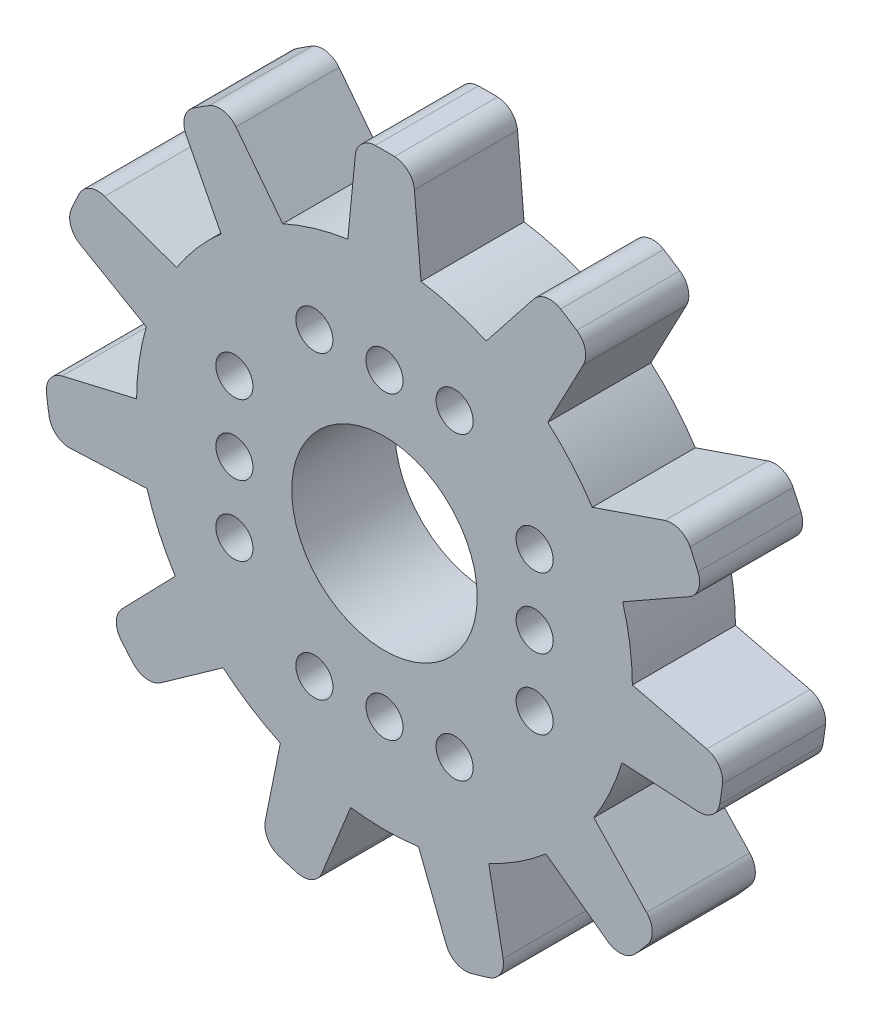
from build123d import *

# Parameters (mm, degrees)
ESBO_O1_R                = 4.5
RESSALTO_EXTRUS_O1_DEPTH = 5
ESBO_O3_R                = 0.9
CORTE_EXTRUS_O4_DEPTH    = 11.8
ESBO_O5_W                = 1.8
ESBO_O5_H                = 6.8
CORTE_EXTRUS_O5_DEPTH    = 1


with BuildPart() as part:
    # Esboço1 → Ressalto-extrusão1 (new body)
    with BuildSketch(Plane.XY):
        with BuildLine():
            Line((7.237292739, 13.882644275), (4.931205446, 10.964033635))
            ThreePointArc((4.931205446, 10.964033635), (3.383365404, 11.536015744), (1.77178072, 11.89065237))
            Line((1.77178072, 11.89065237), (1.451023847, 15.579942687))
            ThreePointArc((1.451023847, 15.579942687), (1.141313879, 16.220426504), (0.484122849, 16.4928962))
            ThreePointArc((0.484122849, 16.4928962), (0.017522037, 16.499990696), (-0.449092791, 16.493887221))
            ThreePointArc((-0.449092791, 16.493887221), (-1.103704511, 16.225768855), (-1.417126065, 15.591599404))
            Line((-1.417126065, 15.591599404), (-1.779210104, 11.889542973))
            ThreePointArc((-1.779210104, 11.889542973), (-3.390572883, 11.533899437), (-4.938055227, 10.960950291))
            Line((-4.938055227, 10.960950291), (-7.202474013, 13.891164545))
            ThreePointArc((-7.202474013, 13.891164545), (-7.809290312, 14.262531969), (-8.509462826, 14.136443768))
            ThreePointArc((-8.509462826, 14.136443768), (-8.905827982, 13.890148593), (-9.295069567, 13.632743002))
            ThreePointArc((-9.295069567, 13.632743002), (-9.700808257, 13.053277663), (-9.621617356, 12.350331887))
            Line((-9.621617356, 12.350331887), (-7.924739018, 9.040206424))
            ThreePointArc((-7.924739018, 9.040206424), (-9.088028236, 7.869851554), (-10.08009353, 6.55122394))
            Line((-10.08009353, 6.55122394), (-13.569237263, 7.792039811))
            ThreePointArc((-13.569237263, 7.792039811), (-14.280500006, 7.776384308), (-14.80135418, 7.291770323))
            ThreePointArc((-14.80135418, 7.291770323), (-15.001640543, 6.870282455), (-15.189927432, 6.443299203))
            ThreePointArc((-15.189927432, 6.443299203), (-15.217973923, 5.736463043), (-14.771313119, 5.187921259))
            Line((-14.771313119, 5.187921259), (-11.554219287, 3.320668211))
            ThreePointArc((-11.554219287, 3.320668211), (-11.900098837, 1.707181407), (-12.02177336, 0.061530278))
            Line((-12.02177336, 0.061530278), (-15.627863558, -0.781002507))
            ThreePointArc((-15.627863558, -0.781002507), (-16.21775185, -1.178710425), (-16.393920163, -1.867988679))
            ThreePointArc((-16.393920163, -1.867988679), (-16.334538228, -2.330849819), (-16.262090664, -2.791846566))
            ThreePointArc((-16.262090664, -2.791846566), (-15.903540395, -3.401638061), (-15.231221337, -3.621617713))
            Line((-15.231221337, -3.621617713), (-11.51531657, -3.453158696))
            ThreePointArc((-11.51531657, -3.453158696), (-10.93397214, -4.997506773), (-10.14662509, -6.447698813))
            Line((-10.14662509, -6.447698813), (-12.724753595, -9.106082048))
            ThreePointArc((-12.724753595, -9.106082048), (-13.005982071, -9.759572927), (-12.781532328, -10.434674473))
            ThreePointArc((-12.781532328, -10.434674473), (-12.48133544, -10.791953745), (-12.171155012, -11.140600777))
            ThreePointArc((-12.171155012, -11.140600777), (-11.53984516, -11.459743115), (-10.855324398, -11.28131865))
            Line((-10.855324398, -11.28131865), (-7.820382206, -9.130632116))
            ThreePointArc((-7.820382206, -9.130632116), (-6.496386543, -10.115521864), (-5.049995046, -10.909829088))
            Line((-5.049995046, -10.909829088), (-5.781624274, -14.540044879))
            ThreePointArc((-5.781624274, -14.540044879), (-5.664904879, -15.241839982), (-5.111098288, -15.68842485))
            ThreePointArc((-5.111098288, -15.68842485), (-4.665396838, -15.826688609), (-4.215963642, -15.952292956))
            ThreePointArc((-4.215963642, -15.952292956), (-3.512330623, -15.879460702), (-3.032938663, -15.359280625))
            Line((-3.032938663, -15.359280625), (-1.642531748, -11.909194354))
            ThreePointArc((-1.642531748, -11.909194354), (0.003755879, -12.021930236), (1.649972743, -11.908165713))
            Line((1.649972743, -11.908165713), (2.997129903, -15.357646195))
            ThreePointArc((2.997129903, -15.357646195), (3.474739585, -15.884930537), (4.182073344, -15.961211187))
            ThreePointArc((4.182073344, -15.961211187), (4.631772295, -15.836561666), (5.077766396, -15.699244836))
            ThreePointArc((5.077766396, -15.699244836), (5.630324069, -15.257561714), (5.752383667, -14.560779526))
            Line((5.752383667, -14.560779526), (5.056810935, -10.90667153))
            ThreePointArc((5.056810935, -10.90667153), (6.502705837, -10.111460701), (7.826085845, -9.125743863))
            Line((7.826085845, -9.125743863), (10.824316513, -11.299303357))
            ThreePointArc((10.824316513, -11.299303357), (11.511178782, -11.484667883), (12.147466239, -11.166425748))
            ThreePointArc((12.147466239, -11.166425748), (12.458386452, -10.81843829), (12.759341481, -10.461797406))
            ThreePointArc((12.759341481, -10.461797406), (12.985390652, -9.791494687), (12.711364828, -9.139333809))
            Line((12.711364828, -9.139333809), (10.150651876, -6.441357558))
            ThreePointArc((10.150651876, -6.441357558), (10.937092637, -4.990673837), (11.517471987, -3.445962816))
            Line((11.517471987, -3.445962816), (15.21485911, -3.65351154))
            ThreePointArc((15.21485911, -3.65351154), (15.89290005, -3.438104324), (16.256124433, -2.826379032))
            ThreePointArc((16.256124433, -2.826379032), (16.329550936, -2.365537195), (16.389915799, -1.902803219))
            ThreePointArc((16.389915799, -1.902803219), (16.217687452, -1.21669728), (15.63457747, -0.816214183))
            Line((15.63457747, -0.816214183), (12.021732567, 0.069041925))
            ThreePointArc((12.021732567, 0.069041925), (11.899029803, 1.714616707), (11.552142152, 3.327887077))
            Line((11.552142152, 3.327887077), (14.774791444, 5.152244377))
            ThreePointArc((14.774791444, 5.152244377), (15.228737846, 5.700033066), (15.203577979, 6.411023056))
            ThreePointArc((15.203577979, 6.411023056), (15.016198378, 6.838405244), (14.816807657, 7.260317546))
            ThreePointArc((14.816807657, 7.260317546), (14.300983076, 7.744392916), (13.593922234, 7.766047679))
            Line((13.593922234, 7.766047679), (10.07599811, 6.557521086))
            ThreePointArc((10.07599811, 6.557521086), (9.083109081, 7.875528562), (7.919088807, 9.045156337))
            Line((7.919088807, 9.045156337), (9.643831887, 12.322199108))
            ThreePointArc((9.643831887, 12.322199108), (9.729558977, 13.028450232), (9.324002941, 13.612970622))
            ThreePointArc((9.324002941, 13.612970622), (8.935308934, 13.871202336), (8.539467774, 14.118338788))
            ThreePointArc((8.539467774, 14.118338788), (7.843817619, 14.246693081), (7.237292739, 13.882644275))
        make_face()
        Circle(ESBO_O1_R, mode=Mode.SUBTRACT)
    extrude(amount=RESSALTO_EXTRUS_O1_DEPTH)

    # Esboço3 → Corte-extrusão4 (cut)
    with BuildSketch(Plane(origin=(0, 0, 0), x_dir=(-1, 0, 0), z_dir=(0, 0, -1))):
        with Locations((3.4, 7.28)):
            Circle(ESBO_O3_R)
        with Locations((0, 7.28)):
            Circle(ESBO_O3_R)
        with Locations((-3.4, 7.28)):
            Circle(ESBO_O3_R)
        with Locations((7.28, -3.4)):
            Circle(ESBO_O3_R)
        with Locations((7.28, 0)):
            Circle(ESBO_O3_R)
        with Locations((7.28, 3.4)):
            Circle(ESBO_O3_R)
        with Locations((-3.4, -7.28)):
            Circle(ESBO_O3_R)
        with Locations((0, -7.28)):
            Circle(ESBO_O3_R)
        with Locations((3.4, -7.28)):
            Circle(ESBO_O3_R)
        with Locations((-7.28, 3.4)):
            Circle(ESBO_O3_R)
        with Locations((-7.28, 0)):
            Circle(ESBO_O3_R)
        with Locations((-7.28, -3.4)):
            Circle(ESBO_O3_R)
    extrude(amount=-CORTE_EXTRUS_O4_DEPTH, mode=Mode.SUBTRACT)

    # Esboço5 → Corte-extrusão5 (cut)
    with BuildSketch(Plane(origin=(0, 0, 0), x_dir=(-1, 0, 0), z_dir=(0, 0, -1))):
        with Locations((7.28, 0)):
            Rectangle(ESBO_O5_W, ESBO_O5_H)
        with Locations((-7.28, 0)):
            Rectangle(ESBO_O5_W, ESBO_O5_H)
    extrude(amount=-CORTE_EXTRUS_O5_DEPTH, mode=Mode.SUBTRACT)


solid = part.part
